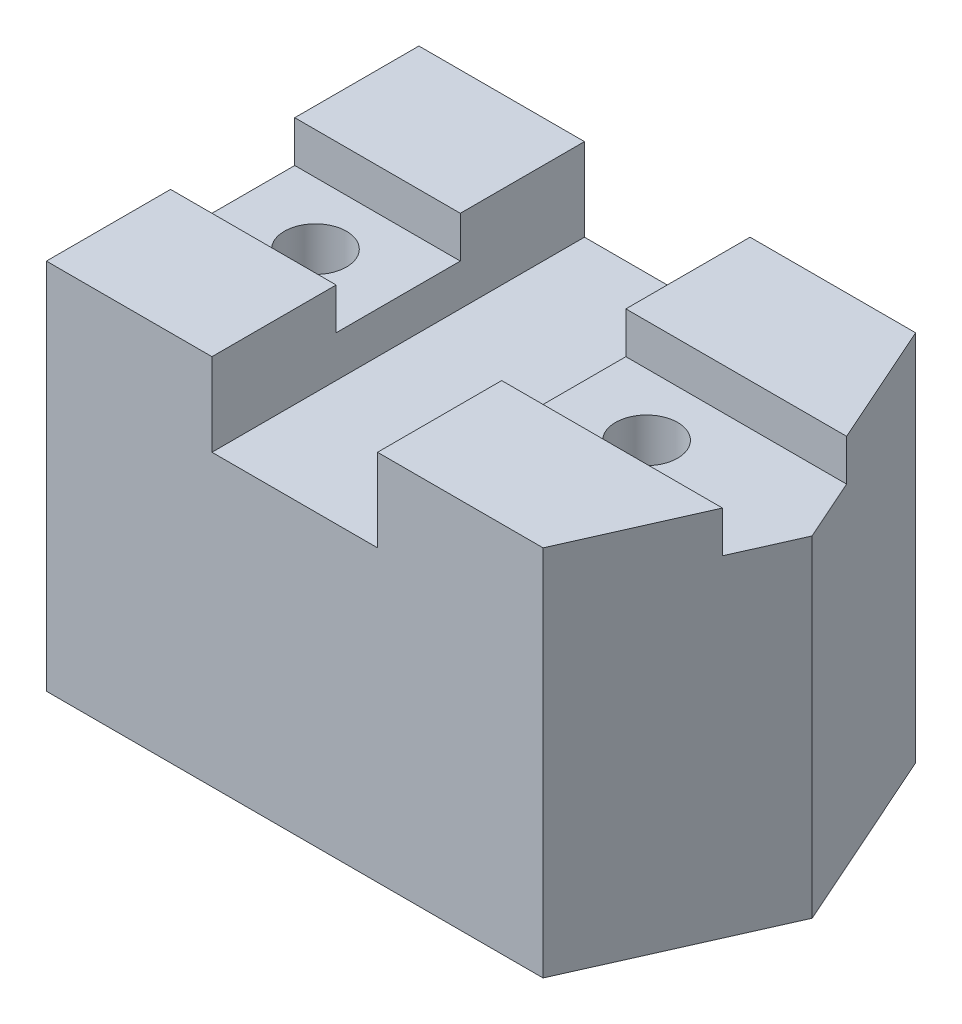
from build123d import *

# Parameters (mm, degrees)
BOSS_EXTRUDE1_DEPTH = 114.3
CUT_EXTRUDE4_DEPTH  = 12.7
SKETCH5_W           = 50.8
SKETCH5_H           = 114.3
CUT_EXTRUDE5_DEPTH  = 25.4
SKETCH6_R           = 9.525
CUT_EXTRUDE6_DEPTH  = 2286
SKETCH7_R           = 9.525
CUT_EXTRUDE7_DEPTH  = 2286


with BuildPart() as part:
    # Sketch2 → Boss-Extrude1 (new body)
    with BuildSketch(Plane(origin=(0, 0, 0), x_dir=(1, 0, 0), z_dir=(0, 1, 0))):
        Polygon((0, 0), (152.4, 0), (177.8, 57.15), (152.4, 114.3), (0, 114.3), align=None)
    extrude(amount=BOSS_EXTRUDE1_DEPTH)

    # Sketch3 → Cut-Extrude4 (cut)
    with BuildSketch(Plane(origin=(0, 114.3, 0), x_dir=(1, 0, 0), z_dir=(0, 1, 0))):
        Polygon((169.333333333, 38.1), (0, 38.1), (0, 76.2), (267.804009423, 76.2), (218.011692499, 38.1), align=None)
    extrude(amount=-CUT_EXTRUDE4_DEPTH, mode=Mode.SUBTRACT)

    # Sketch5 → Cut-Extrude5 (cut)
    with BuildSketch(Plane(origin=(0, 114.3, 0), x_dir=(1, 0, 0), z_dir=(0, 1, 0))):
        with Locations((76.2, 57.15)):
            Rectangle(SKETCH5_W, SKETCH5_H)
    extrude(amount=-CUT_EXTRUDE5_DEPTH, mode=Mode.SUBTRACT)

    # Sketch6 → Cut-Extrude6 (cut)
    with BuildSketch(Plane(origin=(0, 101.6, 0), x_dir=(1, 0, 0), z_dir=(0, 1, 0))):
        with Locations((127, 57.15)):
            Circle(SKETCH6_R)
    extrude(amount=-CUT_EXTRUDE6_DEPTH, mode=Mode.SUBTRACT)

    # Sketch7 → Cut-Extrude7 (cut)
    with BuildSketch(Plane(origin=(0, 101.6, 0), x_dir=(1, 0, 0), z_dir=(0, 1, 0))):
        with Locations((25.4, 57.15)):
            Circle(SKETCH7_R)
    extrude(amount=-CUT_EXTRUDE7_DEPTH, mode=Mode.SUBTRACT)


solid = part.part
